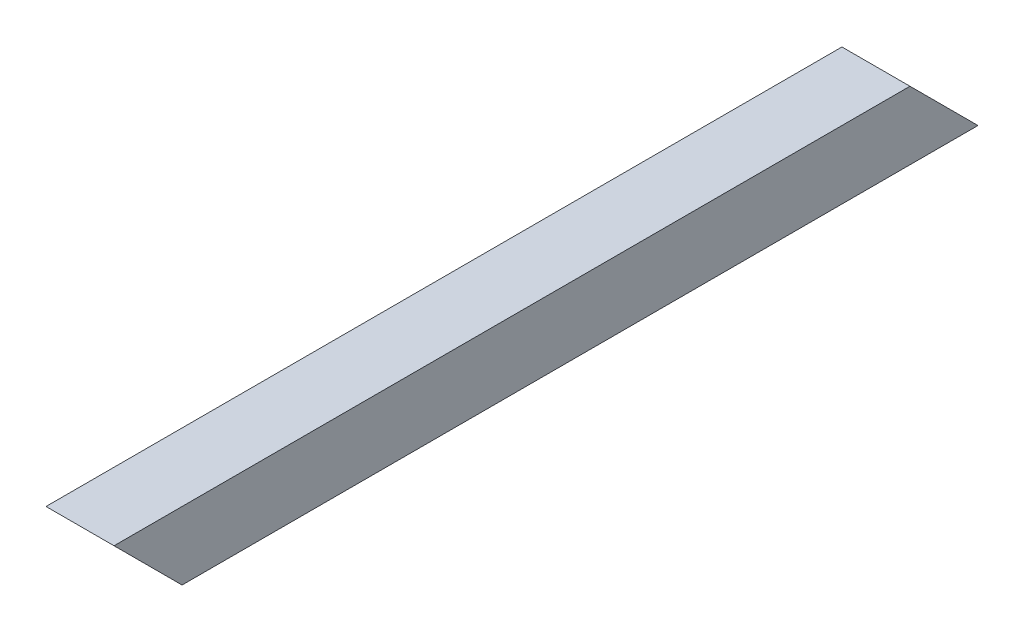
from build123d import *

# Parameters (mm, degrees)
SKETCH3_W           = 25.4
SKETCH3_H           = 25.4
SKETCH3_W_2         = 19.05
SKETCH3_H_2         = 19.05
BOSS_EXTRUDE2_DEPTH = 322.58
CUT_EXTRUDE2_DEPTH  = 299.72
CUT_EXTRUDE3_DEPTH  = 25.4


with BuildPart() as part:
    # Sketch3 → Boss-Extrude2 (new body)
    with BuildSketch(Plane.XY):
        with Locations((-2.765581944, -1.754080231)):
            Rectangle(SKETCH3_W, SKETCH3_H)
        with Locations((-2.765581944, -1.754080231)):
            Rectangle(SKETCH3_W_2, SKETCH3_H_2, mode=Mode.SUBTRACT)
    extrude(amount=BOSS_EXTRUDE2_DEPTH)

    # Sketch4 → Cut-Extrude2 (cut)
    with BuildSketch(Plane.ZY.offset(15.465581944)):
        Polygon((322.58, 10.945919769), (297.18, -14.454080231), (322.58, -14.454080231), align=None)
    extrude(amount=-CUT_EXTRUDE2_DEPTH, mode=Mode.SUBTRACT)

    # Sketch5 → Cut-Extrude3 (cut)
    with BuildSketch(Plane.ZY.offset(15.465581944)):
        Polygon((0, -14.454080231), (25.4, 10.945919769), (0, 10.945919769), align=None)
    extrude(amount=-CUT_EXTRUDE3_DEPTH, mode=Mode.SUBTRACT)


solid = part.part
